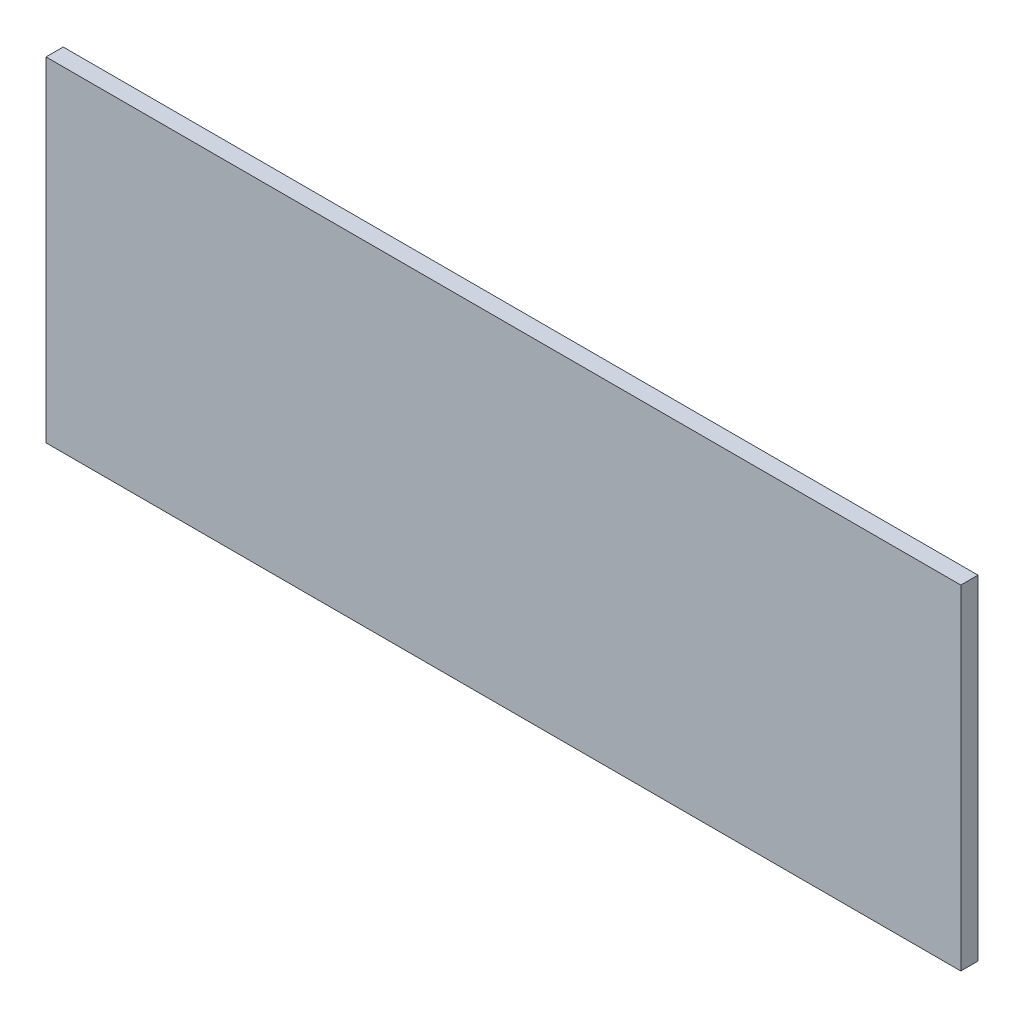
from build123d import *

# Parameters (mm, degrees)
SKETCH1_W           = 266
SKETCH1_H           = 97.192233147
BOSS_EXTRUDE1_DEPTH = 5


with BuildPart() as part:
    # Sketch1 → Boss-Extrude1 (new body)
    with BuildSketch(Plane.XY):
        with Locations((133, -48.596116574)):
            Rectangle(SKETCH1_W, SKETCH1_H)
    extrude(amount=BOSS_EXTRUDE1_DEPTH)


solid = part.part
